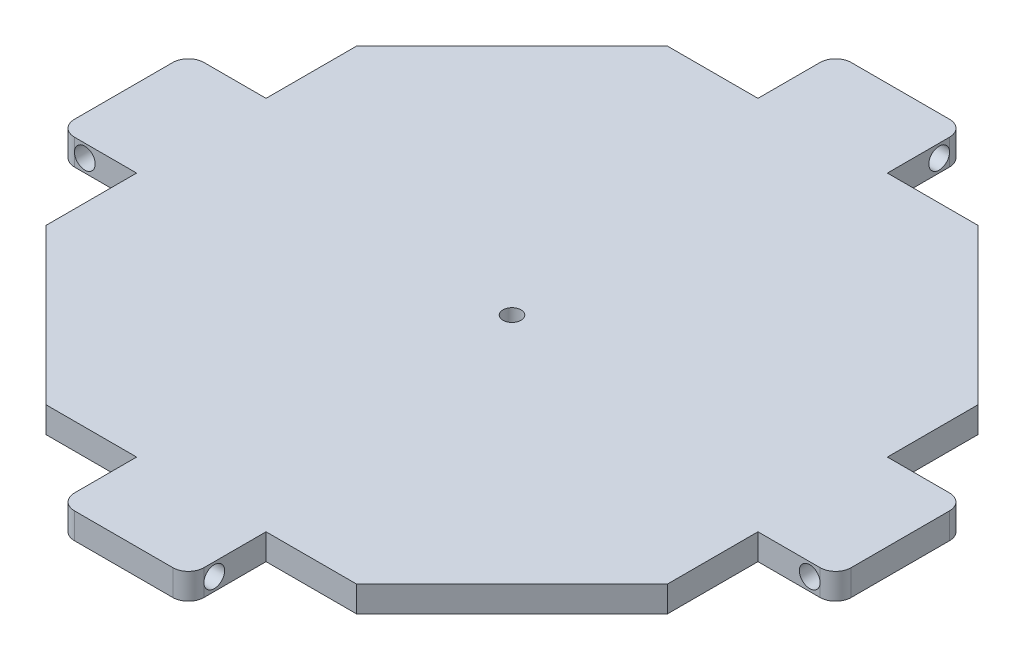
from build123d import *

# Parameters (mm, degrees)
EXTRUDE_1_DEPTH     = 5
FILLET_1_R          = 3
SKETCH_7_R          = 1.75
CUT_EXTRUDE_5_DEPTH = 6
SKETCH_11_R         = 2
CUT_EXTRUDE_6_DEPTH = 88.5
SKETCH_12_R         = 2
CUT_EXTRUDE_7_DEPTH = 88.5


with BuildPart() as part:
    # 스케치1 → 보스-돌출1 (new body)
    with BuildSketch(Plane(origin=(0, 0, 0), x_dir=(1, 0, 0), z_dir=(0, 1, 0))):
        Polygon((-60, -30), (-30, -60), (-12.5, -60), (-12.5, -75), (12.5, -75), (12.5, -60), (30, -60), (60, -30), (60, -12.5), (75, -12.5), (75, 12.5), (60, 12.5), (60, 30), (30, 60), (12.5, 60), (12.5, 75), (-12.5, 75), (-12.5, 60), (-30, 60), (-60, 30), (-60, 12.5), (-75, 12.5), (-75, -12.5), (-60, -12.5), align=None)
    extrude(amount=EXTRUDE_1_DEPTH)

    # 필렛1
    fillet_1_edges = [part.edges().sort_by_distance(p)[0] for p in [
        (-12.5, 2.5, -75),
        (12.5, 2.5, -75),
        (75, 2.5, -12.5),
        (75, 2.5, 12.5),
        (12.5, 2.5, 75),
        (-12.5, 2.5, 75),
        (-75, 2.5, 12.5),
        (-75, 2.5, -12.5),
    ]]
    fillet(fillet_1_edges, radius=FILLET_1_R)

    # 스케치7 → 컷-돌출5 (cut, through all)
    with BuildSketch(Plane(origin=(0, 5, 0), x_dir=(1, 0, 0), z_dir=(0, 1, 0))):
        Circle(SKETCH_7_R)
    extrude(amount=-CUT_EXTRUDE_5_DEPTH, mode=Mode.SUBTRACT)

    # 스케치11 → 컷-돌출6 (cut, through all)
    with BuildSketch(Plane.XY.offset(12.5)):
        with Locations((-70, 2.5)):
            Circle(SKETCH_11_R)
        with Locations((70, 2.5)):
            Circle(SKETCH_11_R)
    extrude(amount=-CUT_EXTRUDE_6_DEPTH, mode=Mode.SUBTRACT)

    # 스케치12 → 컷-돌출7 (cut, through all)
    with BuildSketch(Plane.ZY.offset(12.5)):
        with Locations((-70, 2.5)):
            Circle(SKETCH_12_R)
        with Locations((70, 2.5)):
            Circle(SKETCH_12_R)
    extrude(amount=-CUT_EXTRUDE_7_DEPTH, mode=Mode.SUBTRACT)


solid = part.part
